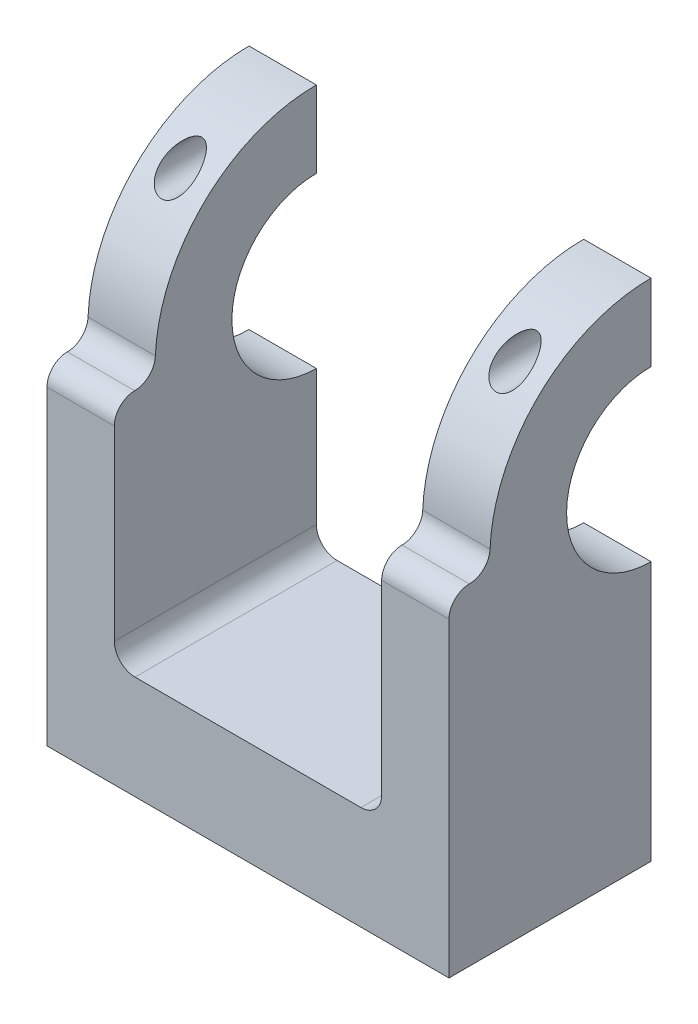
from build123d import *

# Parameters (mm, degrees)
SKETCH3_R            = 15.55
SKETCH3_R_2          = 8.15
BOSS_EXTRUDE4_DEPTH  = 6.5
SKETCH2_R            = 15.55
SKETCH2_R_2          = 8.15
BOSS_EXTRUDE5_DEPTH  = 6.5
CUT_EXTRUDE1_DEPTH   = 38.8
SKETCH5_R            = 1.6
CUT_EXTRUDE2_DEPTH   = 16.55
BOSS_EXTRUDE6_DEPTH  = 6.5
SKETCH9_W            = 6.5
SKETCH9_H            = 21.954006421
BOSS_EXTRUDE7_DEPTH  = 4
BOSS_EXTRUDE8_DEPTH  = 6.5
SKETCH12_W           = 6.5
SKETCH12_H           = 21.954006421
BOSS_EXTRUDE9_DEPTH  = 4
FILLET1_R            = 2
FILLET2_R            = 2
CUT_EXTRUDE3_DEPTH   = 39.8000001
SKETCH13_W           = 19.5
SKETCH13_H           = 10
BOSS_EXTRUDE10_DEPTH = 38.8
FILLET3_R            = 2


with BuildPart() as part:
    # Sketch3 → Boss-Extrude4 (new body)
    with BuildSketch(Plane(origin=(0, 0, 0), x_dir=(0, 0, -1), z_dir=(1, 0, 0))):
        Circle(SKETCH3_R)
        Circle(SKETCH3_R_2, mode=Mode.SUBTRACT)
    extrude(amount=BOSS_EXTRUDE4_DEPTH)


with BuildPart() as body_2:
    # Sketch2 → Boss-Extrude5 (new body)
    with BuildSketch(Plane(origin=(32.3, 0, 0), x_dir=(0, 0, -1), z_dir=(1, 0, 0))):
        Circle(SKETCH2_R)
        Circle(SKETCH2_R_2, mode=Mode.SUBTRACT)
    extrude(amount=BOSS_EXTRUDE5_DEPTH)


with BuildPart() as cut_extrude1_tool:
    # Sketch4 → Cut-Extrude1 (new body)
    with BuildSketch(Plane(origin=(0, 0, 0), x_dir=(0, 0, -1), z_dir=(1, 0, 0))):
        with BuildLine():
            Line((0, 15.55), (0, -15.55))
            ThreePointArc((0, -15.55), (15.55, 0), (0, 15.55))
        make_face()
    extrude(amount=CUT_EXTRUDE1_DEPTH)


with BuildPart() as part_1:
    add(part.part)

    # Cut-Extrude1: cut by cut_extrude1_tool
    add(cut_extrude1_tool.part, mode=Mode.SUBTRACT)


with BuildPart() as body_2_1:
    add(body_2.part)

    # Cut-Extrude1: cut by cut_extrude1_tool
    add(cut_extrude1_tool.part, mode=Mode.SUBTRACT)


with BuildPart() as cut_extrude2_tool:
    # Sketch5 → Cut-Extrude2 (new body, through all)
    with BuildSketch(Plane(origin=(0, 0, 0), x_dir=(-1, 0, 0), z_dir=(0, 0, -1))):
        with Locations((-35.55, 11.85)):
            Circle(SKETCH5_R)
        with Locations((-3.25, 11.85)):
            Circle(SKETCH5_R)
    extrude(amount=-CUT_EXTRUDE2_DEPTH)


with BuildPart() as part_2:
    add(part_1.part)

    # Cut-Extrude2: cut by cut_extrude2_tool
    add(cut_extrude2_tool.part, mode=Mode.SUBTRACT)

    # Sketch11 → Boss-Extrude8 (add)
    with BuildSketch(Plane.ZY):
        with BuildLine():
            ThreePointArc((15.5, -1.245993579), (10.545788255, -11.427547859), (0, -15.55))
            Line((0, -15.55), (0, -23.2))
            Line((0, -23.2), (15.5, -23.2))
            Line((15.5, -23.2), (15.5, -1.245993579))
        make_face()
    extrude(amount=-BOSS_EXTRUDE8_DEPTH)

    # Sketch12 → Boss-Extrude9 (add)
    with BuildSketch(Plane.XY.offset(15.5)):
        with Locations((3.25, -12.22299679)):
            Rectangle(SKETCH12_W, SKETCH12_H)
    extrude(amount=BOSS_EXTRUDE9_DEPTH)

    # Fillet2
    fillet2_edges = [part_2.edges().sort_by_distance(p)[0] for p in [
        (3.25, -1.245993579, 15.5),
    ]]
    fillet(fillet2_edges, radius=FILLET2_R)


with BuildPart() as body_2_2:
    add(body_2_1.part)

    # Cut-Extrude2: cut by cut_extrude2_tool
    add(cut_extrude2_tool.part, mode=Mode.SUBTRACT)

    # Sketch8 → Boss-Extrude6 (add)
    with BuildSketch(Plane(origin=(38.8, 0, 0), x_dir=(0, 0, -1), z_dir=(1, 0, 0))):
        with BuildLine():
            ThreePointArc((0, -19.2), (-8.691551143, -17.120074145), (-15.5, -11.330931118))
            Line((-15.5, -11.330931118), (-15.5, -23.2))
            Line((-15.5, -23.2), (0, -23.2))
            Line((0, -23.2), (0, -19.2))
        make_face()
        with BuildLine():
            ThreePointArc((0, -15.55), (-10.545788255, -11.427547859), (-15.5, -1.245993579))
            Line((-15.5, -1.245993579), (-15.5, -11.330931118))
            ThreePointArc((-15.5, -11.330931118), (-8.691551143, -17.120074145), (0, -19.2))
            Line((0, -19.2), (0, -15.55))
        make_face()
    extrude(amount=-BOSS_EXTRUDE6_DEPTH)

    # Sketch9 → Boss-Extrude7 (add)
    with BuildSketch(Plane.XY.offset(15.5)):
        with Locations((35.55, -12.22299679)):
            Rectangle(SKETCH9_W, SKETCH9_H)
    extrude(amount=BOSS_EXTRUDE7_DEPTH)

    # Fillet1
    fillet1_edges = [body_2_2.edges().sort_by_distance(p)[0] for p in [
        (35.55, -1.245993579, 15.5),
    ]]
    fillet(fillet1_edges, radius=FILLET1_R)


with BuildPart() as cut_extrude3_tool:
    # Sketch10 → Cut-Extrude3 (new body, through all)
    with BuildSketch(Plane(origin=(38.8, 0, 0), x_dir=(0, 0, -1), z_dir=(1, 0, 0))):
        with BuildLine():
            Line((-19.5, -3.212198374), (-19.5, -1.245993579))
            Line((-19.5, -1.245993579), (-17.533795206, -1.245993579))
            ThreePointArc((-17.533795206, -1.245993579), (-18.924111949, -1.82188163), (-19.5, -3.212198374))
        make_face()
    extrude(amount=-CUT_EXTRUDE3_DEPTH)


with BuildPart() as part_3:
    add(part_2.part)

    # Cut-Extrude3: cut by cut_extrude3_tool
    add(cut_extrude3_tool.part, mode=Mode.SUBTRACT)



with BuildPart() as body_2_3:
    add(body_2_2.part)

    # Cut-Extrude3: cut by cut_extrude3_tool
    add(cut_extrude3_tool.part, mode=Mode.SUBTRACT)


with BuildPart() as part_4:
    add(part_3.part)

    add(body_2_3.part)  # Boss-Extrude10 merges body 2
    # Sketch13 → Boss-Extrude10 (add)
    with BuildSketch(Plane(origin=(38.8, 0, 0), x_dir=(0, 0, -1), z_dir=(1, 0, 0))):
        with Locations((-9.75, -28.2)):
            Rectangle(SKETCH13_W, SKETCH13_H)
    extrude(amount=-BOSS_EXTRUDE10_DEPTH)

    # Fillet3
    fillet3_edges = [part_4.edges().sort_by_distance(p)[0] for p in [
        (6.5, -23.2, 9.75),
        (32.3, -23.2, 9.75),
    ]]
    fillet(fillet3_edges, radius=FILLET3_R)


solid = part_4.part
